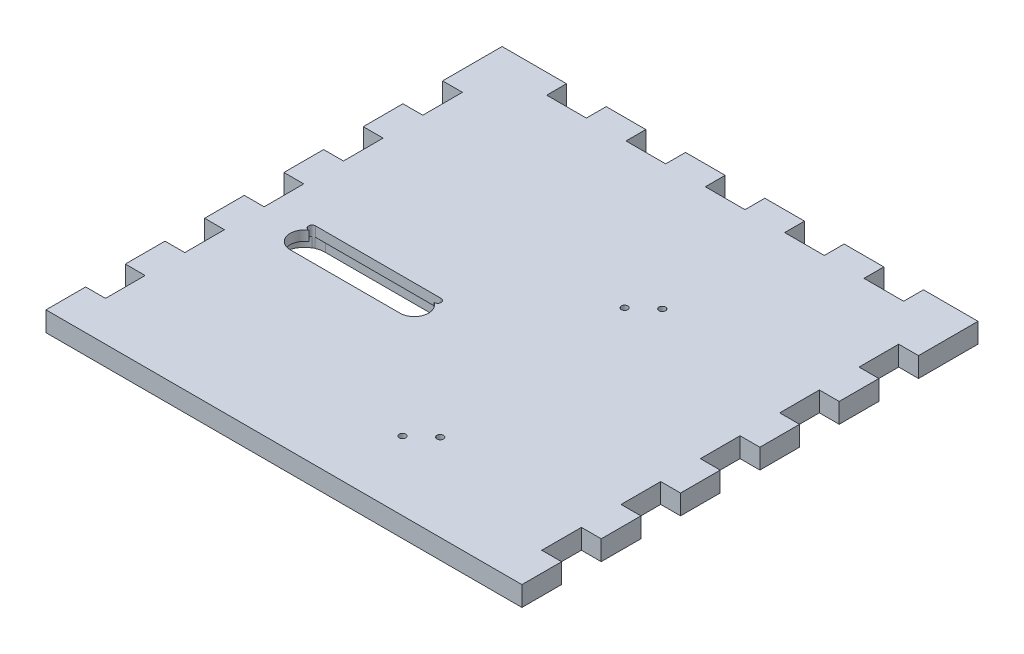
from build123d import *

# Parameters (mm, degrees)
SKETCH1_W               = 279.4
SKETCH1_H               = 279.4
BOSS_EXTRUDE1_DEPTH     = 12.7
SKETCH2_W               = 25.4
SKETCH2_H               = 12.7
BOSS_EXTRUDE2_DEPTH     = 12.7
LPATTERN1_COUNT         = 6
LPATTERN1_PITCH         = 50.8
MIRROR1_COPY_1_SKETCH_W = 25.4
MIRROR1_COPY_1_SKETCH_H = 12.7
MIRROR1_COPY_1_DEPTH    = 12.7
MIRROR1_COPY_2_SKETCH_W = 25.4
MIRROR1_COPY_2_SKETCH_H = 12.7
MIRROR1_COPY_2_DEPTH    = 12.7
MIRROR1_COPY_3_SKETCH_W = 25.4
MIRROR1_COPY_3_SKETCH_H = 12.7
MIRROR1_COPY_3_DEPTH    = 12.7
MIRROR1_COPY_4_SKETCH_W = 25.4
MIRROR1_COPY_4_SKETCH_H = 12.7
MIRROR1_COPY_4_DEPTH    = 12.7
MIRROR1_COPY_5_SKETCH_W = 25.4
MIRROR1_COPY_5_SKETCH_H = 12.7
MIRROR1_COPY_5_DEPTH    = 12.7
MIRROR1_COPY_6_SKETCH_W = 25.4
MIRROR1_COPY_6_SKETCH_H = 12.7
MIRROR1_COPY_6_DEPTH    = 12.7
SKETCH3_W               = 25.4
SKETCH3_H               = 12.7
BOSS_EXTRUDE3_DEPTH     = 12.7
LPATTERN2_COUNT         = 6
LPATTERN2_PITCH         = 50.8
SKETCH5_W               = 25.4
SKETCH5_H               = 12.7
BOSS_EXTRUDE4_DEPTH     = 12.7
SKETCH6_R               = 2.1
CUT_EXTRUDE1_DEPTH      = 216.9
SKETCH7_R               = 4.318
CUT_EXTRUDE2_DEPTH      = 6.35
SKETCH8_R               = 2.2225
CUT_EXTRUDE3_DEPTH      = 216.9
CUT_EXTRUDE5_DEPTH      = 216.9
CUT_EXTRUDE6_DEPTH      = 6.35


with BuildPart() as part:
    # Sketch1 → Boss-Extrude1 (new body)
    with BuildSketch(Plane(origin=(0, 0, 0), x_dir=(1, 0, 0), z_dir=(0, 1, 0))):
        Rectangle(SKETCH1_W, SKETCH1_H)
    extrude(amount=BOSS_EXTRUDE1_DEPTH)

    # Sketch2 → Boss-Extrude2 (add)
    with BuildSketch(Plane(origin=(139.7, 0, 0), x_dir=(0, 0, -1), z_dir=(1, 0, 0))):
        with Locations((-127, 6.35)):
            Rectangle(SKETCH2_W, SKETCH2_H)
    boss_extrude2 = extrude(amount=BOSS_EXTRUDE2_DEPTH)

    # LPattern1: Boss-Extrude2 ×6
    with Locations(*[(0, 0, -i * LPATTERN1_PITCH) for i in range(1, LPATTERN1_COUNT)]):
        add(boss_extrude2)

    # Mirror1 copy 1 sketch → Mirror1 copy 1 (add)
    with BuildSketch(Plane(origin=(-139.7, 0, -50.8), x_dir=(0, 0, -1), z_dir=(-1, 0, 0))):
        with Locations((-127, -6.35)):
            Rectangle(MIRROR1_COPY_1_SKETCH_W, MIRROR1_COPY_1_SKETCH_H)
    extrude(amount=MIRROR1_COPY_1_DEPTH)

    # Mirror1 copy 2 sketch → Mirror1 copy 2 (add)
    with BuildSketch(Plane(origin=(-139.7, 0, -101.6), x_dir=(0, 0, -1), z_dir=(-1, 0, 0))):
        with Locations((-127, -6.35)):
            Rectangle(MIRROR1_COPY_2_SKETCH_W, MIRROR1_COPY_2_SKETCH_H)
    extrude(amount=MIRROR1_COPY_2_DEPTH)

    # Mirror1 copy 3 sketch → Mirror1 copy 3 (add)
    with BuildSketch(Plane(origin=(-139.7, 0, -152.4), x_dir=(0, 0, -1), z_dir=(-1, 0, 0))):
        with Locations((-127, -6.35)):
            Rectangle(MIRROR1_COPY_3_SKETCH_W, MIRROR1_COPY_3_SKETCH_H)
    extrude(amount=MIRROR1_COPY_3_DEPTH)

    # Mirror1 copy 4 sketch → Mirror1 copy 4 (add)
    with BuildSketch(Plane(origin=(-139.7, 0, -203.2), x_dir=(0, 0, -1), z_dir=(-1, 0, 0))):
        with Locations((-127, -6.35)):
            Rectangle(MIRROR1_COPY_4_SKETCH_W, MIRROR1_COPY_4_SKETCH_H)
    extrude(amount=MIRROR1_COPY_4_DEPTH)

    # Mirror1 copy 5 sketch → Mirror1 copy 5 (add)
    with BuildSketch(Plane(origin=(-139.7, 0, -254), x_dir=(0, 0, -1), z_dir=(-1, 0, 0))):
        with Locations((-127, -6.35)):
            Rectangle(MIRROR1_COPY_5_SKETCH_W, MIRROR1_COPY_5_SKETCH_H)
    extrude(amount=MIRROR1_COPY_5_DEPTH)

    # Mirror1 copy 6 sketch → Mirror1 copy 6 (add)
    with BuildSketch(Plane(origin=(-139.7, 0, 0), x_dir=(0, 0, -1), z_dir=(-1, 0, 0))):
        with Locations((-127, -6.35)):
            Rectangle(MIRROR1_COPY_6_SKETCH_W, MIRROR1_COPY_6_SKETCH_H)
    extrude(amount=MIRROR1_COPY_6_DEPTH)

    # Sketch3 → Boss-Extrude3 (add)
    with BuildSketch(Plane(origin=(0, 0, -139.7), x_dir=(-1, 0, 0), z_dir=(0, 0, -1))):
        with Locations((-130.175, 6.35)):
            Rectangle(SKETCH3_W, SKETCH3_H)
    boss_extrude3 = extrude(amount=BOSS_EXTRUDE3_DEPTH)

    # LPattern2: Boss-Extrude3 ×6
    with Locations(*[(-i * LPATTERN2_PITCH, 0, 0) for i in range(1, LPATTERN2_COUNT)]):
        add(boss_extrude3)

    # Sketch5 → Boss-Extrude4 (add)
    with BuildSketch(Plane(origin=(0, 0, -139.7), x_dir=(-1, 0, 0), z_dir=(0, 0, -1))):
        with Locations((-139.7, 6.35)):
            Rectangle(SKETCH5_W, SKETCH5_H)
    boss_extrude4 = extrude(amount=BOSS_EXTRUDE4_DEPTH)

    # Mirror2: Boss-Extrude4 across plane
    add(boss_extrude4.mirror(Plane(origin=(0, 0, 0), x_dir=(0, 0, 1), z_dir=(1, 0, 0))))

    # Sketch6 → Cut-Extrude1 (cut, through all)
    with BuildSketch(Plane.XZ):
        with Locations((44.45, -58.145648771)):
            Circle(SKETCH6_R)
        with Locations((31.75, -46.715648771)):
            Circle(SKETCH6_R)
        with Locations((31.75, 95.524351229)):
            Circle(SKETCH6_R)
        with Locations((44.45, 84.094351229)):
            Circle(SKETCH6_R)
    extrude(amount=-CUT_EXTRUDE1_DEPTH, mode=Mode.SUBTRACT)

    # Sketch7 → Cut-Extrude2 (cut)
    with BuildSketch(Plane.XZ):
        with Locations((31.75, 95.524351229)):
            Circle(SKETCH7_R)
        with Locations((44.45, 84.094351229)):
            Circle(SKETCH7_R)
        with Locations((31.75, -46.715648771)):
            Circle(SKETCH7_R)
        with Locations((44.45, -58.145648771)):
            Circle(SKETCH7_R)
    extrude(amount=-CUT_EXTRUDE2_DEPTH, mode=Mode.SUBTRACT)

    # Sketch8 → Cut-Extrude3 (cut, through all)
    with BuildSketch(Plane(origin=(0, 12.7, 0), x_dir=(1, 0, 0), z_dir=(0, 1, 0))):
        with Locations((-49.920301731, -19.083881859)):
            Circle(SKETCH8_R)
        with Locations((-44.920301731, -9.083881859)):
            Circle(SKETCH8_R)
        with Locations((-94.920301731, -19.083881859)):
            Circle(SKETCH8_R)
        with Locations((-99.920301731, -9.083881859)):
            Circle(SKETCH8_R)
    extrude(amount=-CUT_EXTRUDE3_DEPTH, mode=Mode.SUBTRACT)

    # Sketch10 → Cut-Extrude5 (cut, through all)
    with BuildSketch(Plane.XZ):
        with BuildLine():
            Line((-112.628282809, 11.348870188), (-32.184656299, 11.348870188))
            ThreePointArc((-32.184656299, 11.348870188), (-29.919667971, 9.083881859), (-32.184656299, 6.81889353))
            Line((-32.184656299, 6.81889353), (-112.628282809, 6.81889353))
            ThreePointArc((-112.628282809, 6.81889353), (-114.893271138, 9.083881859), (-112.628282809, 11.348870188))
        make_face()
        with BuildLine():
            Line((-107.547672787, 28.200110176), (-37.142684893, 28.200110176))
            ThreePointArc((-37.142684893, 28.200110176), (-28.026456576, 19.083881859), (-37.142684893, 9.967653542))
            Line((-37.142684893, 9.967653542), (-107.547672787, 9.967653542))
            ThreePointArc((-107.547672787, 9.967653542), (-116.663901104, 19.083881859), (-107.547672787, 28.200110176))
        make_face()
    extrude(amount=-CUT_EXTRUDE5_DEPTH, mode=Mode.SUBTRACT)

    # Sketch12 → Cut-Extrude6 (cut)
    with BuildSketch(Plane.XZ):
        with BuildLine():
            Line((-107.547672787, 32.464365023), (-37.791668277, 32.464365023))
            ThreePointArc((-37.791668277, 32.464365023), (-24.411185114, 19.083881859), (-37.791668277, 5.703398696))
            Line((-37.791668277, 5.703398696), (-107.547672787, 5.703398696))
            ThreePointArc((-107.547672787, 5.703398696), (-120.92815595, 19.083881859), (-107.547672787, 32.464365023))
        make_face()
    extrude(amount=-CUT_EXTRUDE6_DEPTH, mode=Mode.SUBTRACT)


solid = part.part
